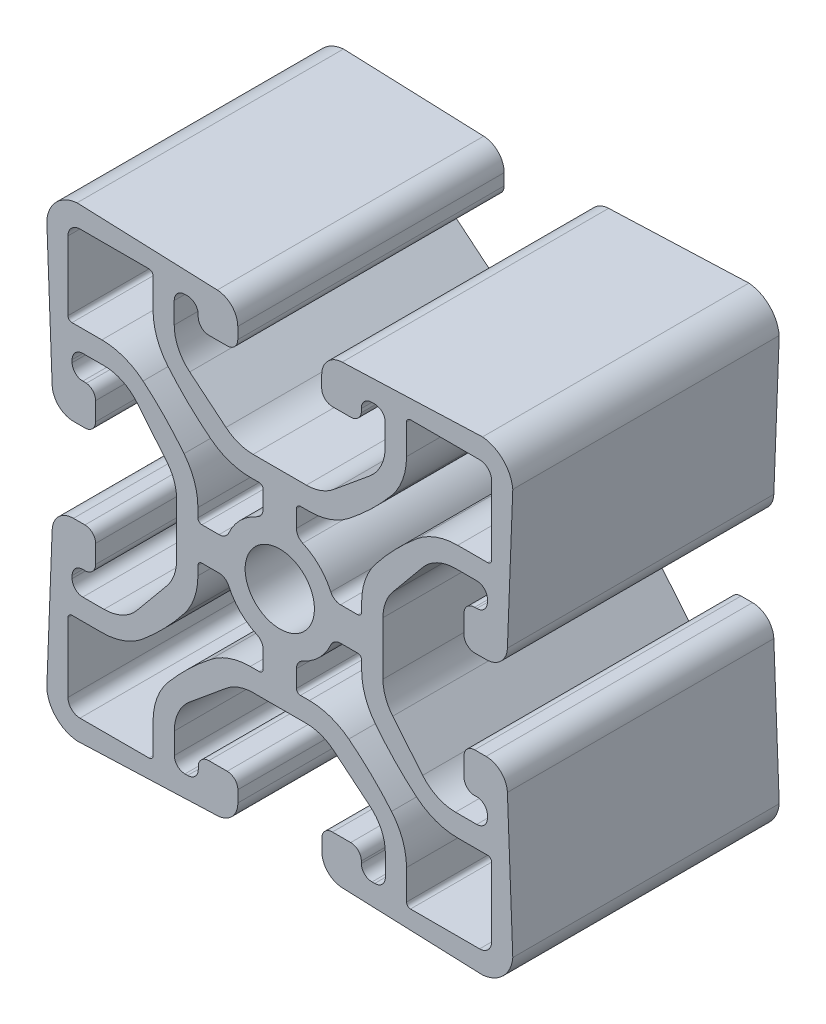
from build123d import *

# Parameters (mm, degrees)
SKETCH1_R      = 3.302
EXTRUDE1_DEPTH = 25.4


with BuildPart() as part:
    # Sketch1 → Extrude1 (new body)
    with BuildSketch(Plane.XY):
        with BuildLine():
            Line((19.325516151, 22.213023214), (5.950440227, 21.699204625))
            ThreePointArc((5.950440227, 21.699204625), (4.564284396, 21.077694894), (3.996444255, 19.668702379))
            Line((3.996444255, 19.668702379), (3.996444255, 18.575111948))
            ThreePointArc((3.996444255, 18.575111948), (4.294023765, 17.856691458), (5.012444255, 17.559111948))
            Line((5.012444255, 17.559111948), (6.762529783, 17.559111948))
            ThreePointArc((6.762529783, 17.559111948), (7.428283667, 17.807630505), (7.768344255, 18.431608472))
            Line((7.768344255, 18.431608472), (7.768344255, 18.443108156))
            Line((7.768344255, 18.443108156), (7.768344255, 18.778311948))
            ThreePointArc((7.768344255, 18.778311948), (8.065923765, 19.496732438), (8.784344255, 19.794311948))
            Line((8.784344255, 19.794311948), (9.038344255, 19.794311948))
            ThreePointArc((9.038344255, 19.794311948), (9.756764745, 19.496732438), (10.054344255, 18.778311948))
            Line((10.054344255, 18.778311948), (10.054344255, 16.755567104))
            ThreePointArc((10.054344255, 16.755567104), (9.666905231, 15.023806325), (8.578460696, 13.622238316))
            Line((8.578460696, 13.622238316), (5.123170571, 10.768183161))
            ThreePointArc((5.123170571, 10.768183161), (3.910235538, 10.077250961), (2.53505413, 9.837511948))
            Line((2.53505413, 9.837511948), (-0.004055745, 9.837511948))
            Line((-0.004055745, 9.837511948), (-2.54316562, 9.837511948))
            ThreePointArc((-2.54316562, 9.837511948), (-3.918347028, 10.077250961), (-5.131282061, 10.768183161))
            Line((-5.131282061, 10.768183161), (-8.586572186, 13.622238316))
            ThreePointArc((-8.586572186, 13.622238316), (-9.675016721, 15.023806325), (-10.062455745, 16.755567104))
            Line((-10.062455745, 16.755567104), (-10.062455745, 18.778311948))
            ThreePointArc((-10.062455745, 18.778311948), (-9.764876235, 19.496732438), (-9.046455745, 19.794311948))
            Line((-9.046455745, 19.794311948), (-8.792455745, 19.794311948))
            ThreePointArc((-8.792455745, 19.794311948), (-8.074035255, 19.496732438), (-7.776455745, 18.778311948))
            Line((-7.776455745, 18.778311948), (-7.776455745, 18.575111948))
            ThreePointArc((-7.776455745, 18.575111948), (-7.478876235, 17.856691458), (-6.760455745, 17.559111948))
            Line((-6.760455745, 17.559111948), (-5.020555745, 17.559111948))
            ThreePointArc((-5.020555745, 17.559111948), (-4.302135255, 17.856691458), (-4.004555745, 18.575111948))
            Line((-4.004555745, 18.575111948), (-4.004555745, 19.668702379))
            ThreePointArc((-4.004555745, 19.668702379), (-4.572395886, 21.077694894), (-5.958551717, 21.699204625))
            Line((-5.958551717, 21.699204625), (-19.327990919, 22.212806673))
            ThreePointArc((-19.327990919, 22.212806673), (-21.295942164, 21.294185553), (-22.213023214, 19.325516151))
            Line((-22.213023214, 19.325516151), (-21.699204625, 5.950440227))
            ThreePointArc((-21.699204625, 5.950440227), (-21.077694894, 4.564284396), (-19.668702379, 3.996444255))
            Line((-19.668702379, 3.996444255), (-18.575111948, 3.996444255))
            ThreePointArc((-18.575111948, 3.996444255), (-17.856691458, 4.294023765), (-17.559111948, 5.012444255))
            Line((-17.559111948, 5.012444255), (-17.559111948, 6.762529783))
            ThreePointArc((-17.559111948, 6.762529783), (-17.807630505, 7.428283667), (-18.431608472, 7.768344255))
            Line((-18.431608472, 7.768344255), (-18.443108156, 7.768344255))
            Line((-18.443108156, 7.768344255), (-18.778311948, 7.768344255))
            ThreePointArc((-18.778311948, 7.768344255), (-19.496732438, 8.065923765), (-19.794311948, 8.784344255))
            Line((-19.794311948, 8.784344255), (-19.794311948, 9.038344255))
            ThreePointArc((-19.794311948, 9.038344255), (-19.496732438, 9.756764745), (-18.778311948, 10.054344255))
            Line((-18.778311948, 10.054344255), (-16.755567104, 10.054344255))
            ThreePointArc((-16.755567104, 10.054344255), (-15.023806325, 9.666905231), (-13.622238316, 8.578460696))
            Line((-13.622238316, 8.578460696), (-10.768183161, 5.123170571))
            ThreePointArc((-10.768183161, 5.123170571), (-10.077250961, 3.910235538), (-9.837511948, 2.53505413))
            Line((-9.837511948, 2.53505413), (-9.837511948, -0.004055745))
            Line((-9.837511948, -0.004055745), (-9.837511948, -2.54316562))
            ThreePointArc((-9.837511948, -2.54316562), (-10.077250961, -3.918347028), (-10.768183161, -5.131282061))
            Line((-10.768183161, -5.131282061), (-13.622238316, -8.586572186))
            ThreePointArc((-13.622238316, -8.586572186), (-15.023806325, -9.675016721), (-16.755567104, -10.062455745))
            Line((-16.755567104, -10.062455745), (-18.778311948, -10.062455745))
            ThreePointArc((-18.778311948, -10.062455745), (-19.496732438, -9.764876235), (-19.794311948, -9.046455745))
            Line((-19.794311948, -9.046455745), (-19.794311948, -8.792455745))
            ThreePointArc((-19.794311948, -8.792455745), (-19.496732438, -8.074035255), (-18.778311948, -7.776455745))
            Line((-18.778311948, -7.776455745), (-18.575111948, -7.776455745))
            ThreePointArc((-18.575111948, -7.776455745), (-17.856691458, -7.478876235), (-17.559111948, -6.760455745))
            Line((-17.559111948, -6.760455745), (-17.559111948, -5.020555745))
            ThreePointArc((-17.559111948, -5.020555745), (-17.856691458, -4.302135255), (-18.575111948, -4.004555745))
            Line((-18.575111948, -4.004555745), (-19.668702379, -4.004555745))
            ThreePointArc((-19.668702379, -4.004555745), (-21.077694894, -4.572395886), (-21.699204625, -5.958551717))
            Line((-21.699204625, -5.958551717), (-22.212806673, -19.327990919))
            ThreePointArc((-22.212806673, -19.327990919), (-21.294185553, -21.295942164), (-19.325516151, -22.213023214))
            Line((-19.325516151, -22.213023214), (-5.950440227, -21.699204625))
            ThreePointArc((-5.950440227, -21.699204625), (-4.564284396, -21.077694894), (-3.996444255, -19.668702379))
            Line((-3.996444255, -19.668702379), (-3.996444255, -18.575111948))
            ThreePointArc((-3.996444255, -18.575111948), (-4.294023765, -17.856691458), (-5.012444255, -17.559111948))
            Line((-5.012444255, -17.559111948), (-6.762529783, -17.559111948))
            ThreePointArc((-6.762529783, -17.559111948), (-7.428283667, -17.807630505), (-7.768344255, -18.431608472))
            Line((-7.768344255, -18.431608472), (-7.768344255, -18.443108156))
            Line((-7.768344255, -18.443108156), (-7.768344255, -18.778311948))
            ThreePointArc((-7.768344255, -18.778311948), (-8.065923765, -19.496732438), (-8.784344255, -19.794311948))
            Line((-8.784344255, -19.794311948), (-9.038344255, -19.794311948))
            ThreePointArc((-9.038344255, -19.794311948), (-9.756764745, -19.496732438), (-10.054344255, -18.778311948))
            Line((-10.054344255, -18.778311948), (-10.054344255, -16.755567104))
            ThreePointArc((-10.054344255, -16.755567104), (-9.666905231, -15.023806325), (-8.578460696, -13.622238316))
            Line((-8.578460696, -13.622238316), (-5.123170571, -10.768183161))
            ThreePointArc((-5.123170571, -10.768183161), (-3.910235538, -10.077250961), (-2.53505413, -9.837511948))
            Line((-2.53505413, -9.837511948), (0.004055745, -9.837511948))
            Line((0.004055745, -9.837511948), (2.54316562, -9.837511948))
            ThreePointArc((2.54316562, -9.837511948), (3.918347028, -10.077250961), (5.131282061, -10.768183161))
            Line((5.131282061, -10.768183161), (8.586572186, -13.622238316))
            ThreePointArc((8.586572186, -13.622238316), (9.675016721, -15.023806325), (10.062455745, -16.755567104))
            Line((10.062455745, -16.755567104), (10.062455745, -18.778311948))
            ThreePointArc((10.062455745, -18.778311948), (9.764876235, -19.496732438), (9.046455745, -19.794311948))
            Line((9.046455745, -19.794311948), (8.792455745, -19.794311948))
            ThreePointArc((8.792455745, -19.794311948), (8.074035255, -19.496732438), (7.776455745, -18.778311948))
            Line((7.776455745, -18.778311948), (7.776455745, -18.575111948))
            ThreePointArc((7.776455745, -18.575111948), (7.478876235, -17.856691458), (6.760455745, -17.559111948))
            Line((6.760455745, -17.559111948), (5.020555745, -17.559111948))
            ThreePointArc((5.020555745, -17.559111948), (4.302135255, -17.856691458), (4.004555745, -18.575111948))
            Line((4.004555745, -18.575111948), (4.004555745, -19.668702379))
            ThreePointArc((4.004555745, -19.668702379), (4.572395886, -21.077694894), (5.958551717, -21.699204625))
            Line((5.958551717, -21.699204625), (19.327990919, -22.212806673))
            ThreePointArc((19.327990919, -22.212806673), (21.295942164, -21.294185553), (22.213023214, -19.325516151))
            Line((22.213023214, -19.325516151), (21.699204625, -5.950440227))
            ThreePointArc((21.699204625, -5.950440227), (21.077694894, -4.564284396), (19.668702379, -3.996444255))
            Line((19.668702379, -3.996444255), (18.575111948, -3.996444255))
            ThreePointArc((18.575111948, -3.996444255), (17.856691458, -4.294023765), (17.559111948, -5.012444255))
            Line((17.559111948, -5.012444255), (17.559111948, -6.762529783))
            ThreePointArc((17.559111948, -6.762529783), (17.807630505, -7.428283667), (18.431608472, -7.768344255))
            Line((18.431608472, -7.768344255), (18.443108156, -7.768344255))
            Line((18.443108156, -7.768344255), (18.778311948, -7.768344255))
            ThreePointArc((18.778311948, -7.768344255), (19.496732438, -8.065923765), (19.794311948, -8.784344255))
            Line((19.794311948, -8.784344255), (19.794311948, -9.038344255))
            ThreePointArc((19.794311948, -9.038344255), (19.496732438, -9.756764745), (18.778311948, -10.054344255))
            Line((18.778311948, -10.054344255), (16.755567104, -10.054344255))
            ThreePointArc((16.755567104, -10.054344255), (15.023806325, -9.666905231), (13.622238316, -8.578460696))
            Line((13.622238316, -8.578460696), (10.768183161, -5.123170571))
            ThreePointArc((10.768183161, -5.123170571), (10.077250961, -3.910235538), (9.837511948, -2.53505413))
            Line((9.837511948, -2.53505413), (9.837511948, 0.004055745))
            Line((9.837511948, 0.004055745), (9.837511948, 2.54316562))
            ThreePointArc((9.837511948, 2.54316562), (10.077250961, 3.918347028), (10.768183161, 5.131282061))
            Line((10.768183161, 5.131282061), (13.622238316, 8.586572186))
            ThreePointArc((13.622238316, 8.586572186), (15.023806325, 9.675016721), (16.755567104, 10.062455745))
            Line((16.755567104, 10.062455745), (18.778311948, 10.062455745))
            ThreePointArc((18.778311948, 10.062455745), (19.496732438, 9.764876235), (19.794311948, 9.046455745))
            Line((19.794311948, 9.046455745), (19.794311948, 8.792455745))
            ThreePointArc((19.794311948, 8.792455745), (19.496732438, 8.074035255), (18.778311948, 7.776455745))
            Line((18.778311948, 7.776455745), (18.575111948, 7.776455745))
            ThreePointArc((18.575111948, 7.776455745), (17.856691458, 7.478876235), (17.559111948, 6.760455745))
            Line((17.559111948, 6.760455745), (17.559111948, 5.020555745))
            ThreePointArc((17.559111948, 5.020555745), (17.856691458, 4.302135255), (18.575111948, 4.004555745))
            Line((18.575111948, 4.004555745), (19.668702379, 4.004555745))
            ThreePointArc((19.668702379, 4.004555745), (21.077694894, 4.572395886), (21.699204625, 5.958551717))
            Line((21.699204625, 5.958551717), (22.212806673, 19.327990919))
            ThreePointArc((22.212806673, 19.327990919), (21.294185553, 21.295942164), (19.325516151, 22.213023214))
        make_face()
        Circle(SKETCH1_R, mode=Mode.SUBTRACT)
        with BuildLine():
            Line((-1.5875, -7.424511948), (-1.5875, -5.791743067))
            ThreePointArc((-1.5875, -5.791743067), (-1.750422934, -5.239913818), (-2.18694, -4.865064176))
            ThreePointArc((-2.18694, -4.865064176), (-3.771707571, -3.771707571), (-4.865064176, -2.18694))
            ThreePointArc((-4.865064176, -2.18694), (-5.239913818, -1.750422934), (-5.791743067, -1.5875))
            Line((-5.791743067, -1.5875), (-7.424511948, -1.5875))
            ThreePointArc((-7.424511948, -1.5875), (-7.693919632, -1.699092316), (-7.805511948, -1.9685))
            Line((-7.805511948, -1.9685), (-7.805511948, -2.819770332))
            ThreePointArc((-7.805511948, -2.819770332), (-8.139382422, -4.809513866), (-9.104422489, -6.581305753))
            ThreePointArc((-9.104422489, -6.581305753), (-10.966410912, -8.718561331), (-13.039009154, -10.652262139))
            ThreePointArc((-13.039009154, -10.652262139), (-14.874150794, -11.713474326), (-16.96174596, -12.082069816))
            Line((-16.96174596, -12.082069816), (-19.812, -12.082069816))
            ThreePointArc((-19.812, -12.082069816), (-20.081407684, -12.193662132), (-20.193, -12.463069816))
            Line((-20.193, -12.463069816), (-20.193, -19.05))
            ThreePointArc((-20.193, -19.05), (-19.858223051, -19.858223051), (-19.05, -20.193))
            Line((-19.05, -20.193), (-12.463069816, -20.193))
            ThreePointArc((-12.463069816, -20.193), (-12.193662132, -20.081407684), (-12.082069816, -19.812))
            Line((-12.082069816, -19.812), (-12.082069816, -16.96174596))
            ThreePointArc((-12.082069816, -16.96174596), (-11.712247623, -14.87078835), (-10.647652583, -13.033532357))
            ThreePointArc((-10.647652583, -13.033532357), (-8.726025703, -10.977204118), (-6.603816454, -9.128592858))
            ThreePointArc((-6.603816454, -9.128592858), (-4.819829804, -8.145778686), (-2.811658842, -7.805511948))
            Line((-2.811658842, -7.805511948), (-1.9685, -7.805511948))
            ThreePointArc((-1.9685, -7.805511948), (-1.699092316, -7.693919632), (-1.5875, -7.424511948))
        make_face(mode=Mode.SUBTRACT)
        with BuildLine():
            Line((-7.424511948, 1.5875), (-5.791743067, 1.5875))
            ThreePointArc((-5.791743067, 1.5875), (-5.239913818, 1.750422934), (-4.865064176, 2.18694))
            ThreePointArc((-4.865064176, 2.18694), (-3.771707571, 3.771707571), (-2.18694, 4.865064176))
            ThreePointArc((-2.18694, 4.865064176), (-1.750422934, 5.239913818), (-1.5875, 5.791743067))
            Line((-1.5875, 5.791743067), (-1.5875, 7.424511948))
            ThreePointArc((-1.5875, 7.424511948), (-1.699092316, 7.693919632), (-1.9685, 7.805511948))
            Line((-1.9685, 7.805511948), (-2.819770332, 7.805511948))
            ThreePointArc((-2.819770332, 7.805511948), (-4.809513866, 8.139382422), (-6.581305753, 9.104422489))
            ThreePointArc((-6.581305753, 9.104422489), (-8.718561331, 10.966410912), (-10.652262139, 13.039009154))
            ThreePointArc((-10.652262139, 13.039009154), (-11.713474326, 14.874150794), (-12.082069816, 16.96174596))
            Line((-12.082069816, 16.96174596), (-12.082069816, 19.812))
            ThreePointArc((-12.082069816, 19.812), (-12.193662132, 20.081407684), (-12.463069816, 20.193))
            Line((-12.463069816, 20.193), (-19.05, 20.193))
            ThreePointArc((-19.05, 20.193), (-19.858223051, 19.858223051), (-20.193, 19.05))
            Line((-20.193, 19.05), (-20.193, 12.463069816))
            ThreePointArc((-20.193, 12.463069816), (-20.081407684, 12.193662132), (-19.812, 12.082069816))
            Line((-19.812, 12.082069816), (-16.96174596, 12.082069816))
            ThreePointArc((-16.96174596, 12.082069816), (-14.87078835, 11.712247623), (-13.033532357, 10.647652583))
            ThreePointArc((-13.033532357, 10.647652583), (-10.977204118, 8.726025703), (-9.128592858, 6.603816454))
            ThreePointArc((-9.128592858, 6.603816454), (-8.145778686, 4.819829804), (-7.805511948, 2.811658842))
            Line((-7.805511948, 2.811658842), (-7.805511948, 1.9685))
            ThreePointArc((-7.805511948, 1.9685), (-7.693919632, 1.699092316), (-7.424511948, 1.5875))
        make_face(mode=Mode.SUBTRACT)
        with BuildLine():
            Line((7.424511948, -1.5875), (5.791743067, -1.5875))
            ThreePointArc((5.791743067, -1.5875), (5.239913818, -1.750422934), (4.865064176, -2.18694))
            ThreePointArc((4.865064176, -2.18694), (3.771707571, -3.771707571), (2.18694, -4.865064176))
            ThreePointArc((2.18694, -4.865064176), (1.750422934, -5.239913818), (1.5875, -5.791743067))
            Line((1.5875, -5.791743067), (1.5875, -7.424511948))
            ThreePointArc((1.5875, -7.424511948), (1.699092316, -7.693919632), (1.9685, -7.805511948))
            Line((1.9685, -7.805511948), (2.819770332, -7.805511948))
            ThreePointArc((2.819770332, -7.805511948), (4.809513866, -8.139382422), (6.581305753, -9.104422489))
            ThreePointArc((6.581305753, -9.104422489), (8.718561331, -10.966410912), (10.652262139, -13.039009154))
            ThreePointArc((10.652262139, -13.039009154), (11.713474326, -14.874150794), (12.082069816, -16.96174596))
            Line((12.082069816, -16.96174596), (12.082069816, -19.812))
            ThreePointArc((12.082069816, -19.812), (12.193662132, -20.081407684), (12.463069816, -20.193))
            Line((12.463069816, -20.193), (19.05, -20.193))
            ThreePointArc((19.05, -20.193), (19.858223051, -19.858223051), (20.193, -19.05))
            Line((20.193, -19.05), (20.193, -12.463069816))
            ThreePointArc((20.193, -12.463069816), (20.081407684, -12.193662132), (19.812, -12.082069816))
            Line((19.812, -12.082069816), (16.96174596, -12.082069816))
            ThreePointArc((16.96174596, -12.082069816), (14.87078835, -11.712247623), (13.033532357, -10.647652583))
            ThreePointArc((13.033532357, -10.647652583), (10.977204118, -8.726025703), (9.128592858, -6.603816454))
            ThreePointArc((9.128592858, -6.603816454), (8.145778686, -4.819829804), (7.805511948, -2.811658842))
            Line((7.805511948, -2.811658842), (7.805511948, -1.9685))
            ThreePointArc((7.805511948, -1.9685), (7.693919632, -1.699092316), (7.424511948, -1.5875))
        make_face(mode=Mode.SUBTRACT)
        with BuildLine():
            Line((7.805511948, 2.819770332), (7.805511948, 1.9685))
            ThreePointArc((7.805511948, 1.9685), (7.693919632, 1.699092316), (7.424511948, 1.5875))
            Line((7.424511948, 1.5875), (5.791743067, 1.5875))
            ThreePointArc((5.791743067, 1.5875), (5.239913818, 1.750422934), (4.865064176, 2.18694))
            ThreePointArc((4.865064176, 2.18694), (3.771707571, 3.771707571), (2.18694, 4.865064176))
            ThreePointArc((2.18694, 4.865064176), (1.750422934, 5.239913818), (1.5875, 5.791743067))
            Line((1.5875, 5.791743067), (1.5875, 7.424511948))
            ThreePointArc((1.5875, 7.424511948), (1.699092316, 7.693919632), (1.9685, 7.805511948))
            Line((1.9685, 7.805511948), (2.811658842, 7.805511948))
            ThreePointArc((2.811658842, 7.805511948), (4.819829804, 8.145778686), (6.603816454, 9.128592858))
            ThreePointArc((6.603816454, 9.128592858), (8.726025703, 10.977204118), (10.647652583, 13.033532357))
            ThreePointArc((10.647652583, 13.033532357), (11.712247623, 14.87078835), (12.082069816, 16.96174596))
            Line((12.082069816, 16.96174596), (12.082069816, 19.812))
            ThreePointArc((12.082069816, 19.812), (12.193662132, 20.081407684), (12.463069816, 20.193))
            Line((12.463069816, 20.193), (19.05, 20.193))
            ThreePointArc((19.05, 20.193), (19.858223051, 19.858223051), (20.193, 19.05))
            Line((20.193, 19.05), (20.193, 12.463069816))
            ThreePointArc((20.193, 12.463069816), (20.081407684, 12.193662132), (19.812, 12.082069816))
            Line((19.812, 12.082069816), (16.96174596, 12.082069816))
            ThreePointArc((16.96174596, 12.082069816), (14.874150794, 11.713474326), (13.039009154, 10.652262139))
            ThreePointArc((13.039009154, 10.652262139), (10.966410912, 8.718561331), (9.104422489, 6.581305753))
            ThreePointArc((9.104422489, 6.581305753), (8.139382422, 4.809513866), (7.805511948, 2.819770332))
        make_face(mode=Mode.SUBTRACT)
    extrude(amount=EXTRUDE1_DEPTH)


solid = part.part
